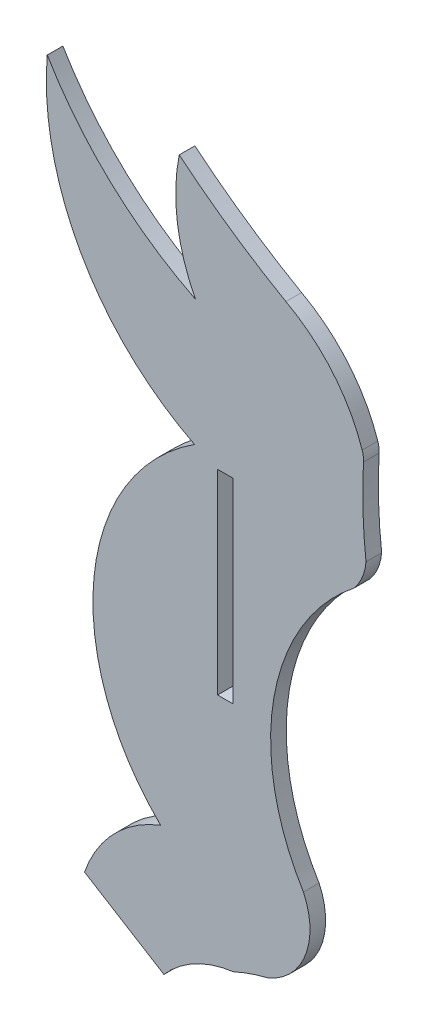
from build123d import *

# Parameters (mm, degrees)
SKETCH1_W           = 1.524
SKETCH1_H           = 19.05
BOSS_EXTRUDE1_DEPTH = 1.524


with BuildPart() as part:
    # Sketch1 → Boss-Extrude1 (new body)
    with BuildSketch(Plane.XY):
        with BuildLine():
            Line((-12.968401667, -214.533069625), (-5.231008599, -219.308220204))
            ThreePointArc((-5.231008599, -219.308220204), (-2.186267033, -216.881335926), (1.524, -215.700600116))
            ThreePointArc((1.524, -215.700600116), (3.189789502, -215.033578347), (4.911266579, -214.527328034))
            ThreePointArc((4.911266579, -214.527328034), (8.56652215, -210.778134694), (8.366250568, -205.545808702))
            ThreePointArc((8.366250568, -205.545808702), (5.494506116, -190.54054727), (13.311403321, -177.414203341))
            ThreePointArc((13.311403321, -177.414203341), (14.109075531, -176.108897248), (14.468404268, -174.621958174))
            ThreePointArc((14.468404268, -174.621958174), (14.169609027, -170.48015642), (14.223154403, -166.327936138))
            ThreePointArc((14.223154403, -166.327936138), (14.204082667, -165.84665661), (14.094500503, -165.377630529))
            ThreePointArc((14.094500503, -165.377630529), (11.21769373, -160.262840376), (6.664633993, -156.56057856))
            ThreePointArc((6.664633993, -156.56057856), (1.308827331, -153.190269752), (-3.738486028, -149.373428868))
            ThreePointArc((-3.738486028, -149.373428868), (-3.917462061, -155.201242728), (-2.164967532, -160.762196757))
            ThreePointArc((-2.164967532, -160.762196757), (-10.348444798, -155.111050325), (-16.602878059, -147.37885654))
            ThreePointArc((-16.602878059, -147.37885654), (-13.34872328, -162.415016966), (-2.254215141, -173.07276217))
            ThreePointArc((-2.254215141, -173.07276217), (-12.048739338, -189.17955679), (-5.548621032, -206.874471292))
            ThreePointArc((-5.548621032, -206.874471292), (-10.108356413, -209.880426072), (-12.968401667, -214.533069625))
        make_face()
        with Locations((0.762, -183.574694423)):
            Rectangle(SKETCH1_W, SKETCH1_H, mode=Mode.SUBTRACT)
    extrude(amount=BOSS_EXTRUDE1_DEPTH)


solid = part.part
